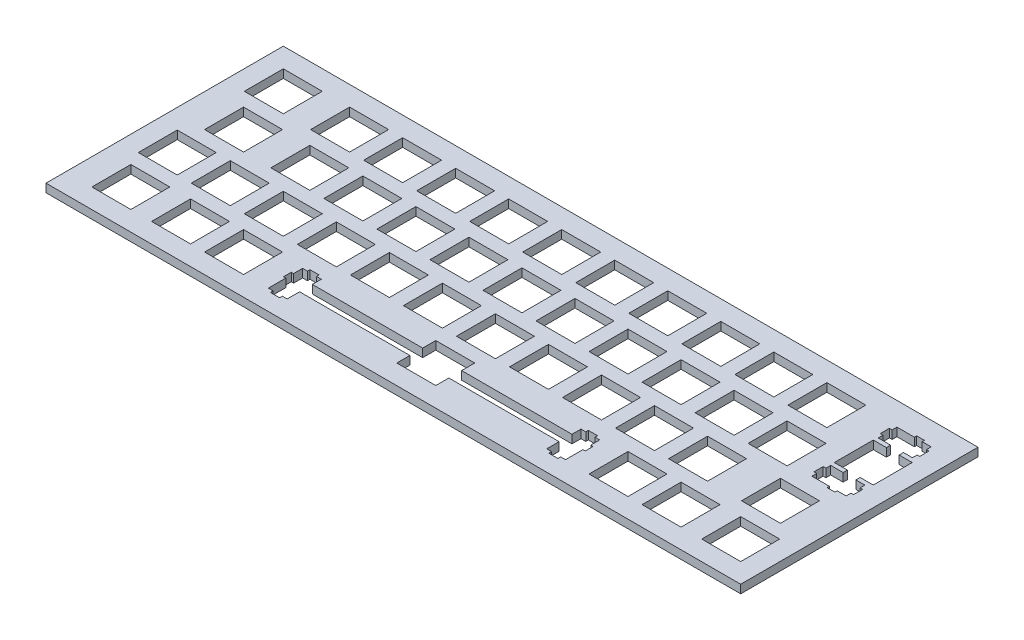
from build123d import *

# Parameters (mm, degrees)
ESQUISSE4_W        = 249.55535
ESQUISSE4_H        = 85.24946
ESQUISSE4_W_2      = 13.999
ESQUISSE4_H_2      = 13.99946
ESQUISSE4_W_3      = 13.9993
ESQUISSE4_W_4      = 13.99949
ESQUISSE4_W_5      = 14.001
ESQUISSE4_H_3      = 13.9994
ESQUISSE4_W_6      = 14.0007
ESQUISSE4_W_7      = 13.99955
ESQUISSE4_H_4      = 13.9993
ESQUISSE4_W_8      = 13.99954
ESQUISSE4_W_9      = 14
BOSS_EXTRU_2_DEPTH = 3


with BuildPart() as part:
    # Esquisse4 → Boss.-Extru.2 (new body)
    with BuildSketch(Plane(origin=(0, 0, 0), x_dir=(1, 0, 0), z_dir=(0, 1, 0))):
        with Locations((120.347325, 38.35837)):
            Rectangle(ESQUISSE4_W, ESQUISSE4_H)
        Polygon((114.537, 16.7831), (114.537, 12.0826), (74.9131, 12.0826), (74.9131, 15.3128), (73.1876, 15.3128), (73.1876, 16.2347), (69.887, 16.2347), (69.887, 15.3128), (68.162, 15.3128), (68.162, 12.0826), (67.3379, 12.0826), (67.3379, 9.28384), (68.162, 9.28384), (68.162, 3.01377), (69.887, 3.01377), (69.887, 2.03261), (73.1876, 2.03261), (73.1876, 3.01377), (74.9131, 3.01377), (74.9131, 7.48273), (114.537, 7.48273), (114.537, 2.78364), (128.538, 2.78364), (128.538, 7.48273), (168.162, 7.48273), (168.162, 3.01377), (169.887, 3.01377), (169.887, 2.03261), (173.188, 2.03261), (173.188, 3.01377), (174.913, 3.01377), (174.913, 9.28384), (175.737, 9.28384), (175.737, 12.0826), (174.913, 12.0826), (174.913, 15.3128), (173.188, 15.3128), (173.188, 16.2347), (169.887, 16.2347), (169.887, 15.3128), (168.162, 15.3128), (168.162, 12.0826), (128.538, 12.0826), (128.538, 16.7831), align=None, mode=Mode.SUBTRACT)
        with Locations((231.0755, 9.78337)):
            Rectangle(ESQUISSE4_W_2, ESQUISSE4_H_2, mode=Mode.SUBTRACT)
        with Locations((209.6445, 9.78337)):
            Rectangle(ESQUISSE4_W_2, ESQUISSE4_H_2, mode=Mode.SUBTRACT)
        with Locations((190.5945, 9.78337)):
            Rectangle(ESQUISSE4_W_2, ESQUISSE4_H_2, mode=Mode.SUBTRACT)
        with Locations((52.48185, 9.78337)):
            Rectangle(ESQUISSE4_W_3, ESQUISSE4_H_2, mode=Mode.SUBTRACT)
        with Locations((33.43185, 9.78337)):
            Rectangle(ESQUISSE4_W_3, ESQUISSE4_H_2, mode=Mode.SUBTRACT)
        with Locations((12.000655, 9.78337)):
            Rectangle(ESQUISSE4_W_4, ESQUISSE4_H_2, mode=Mode.SUBTRACT)
        with Locations((226.3125, 28.8333)):
            Rectangle(ESQUISSE4_W_5, ESQUISSE4_H_3, mode=Mode.SUBTRACT)
        with Locations((200.1195, 28.8333)):
            Rectangle(ESQUISSE4_W_2, ESQUISSE4_H_3, mode=Mode.SUBTRACT)
        with Locations((181.0695, 28.8333)):
            Rectangle(ESQUISSE4_W_2, ESQUISSE4_H_3, mode=Mode.SUBTRACT)
        with Locations((162.0195, 28.8333)):
            Rectangle(ESQUISSE4_W_2, ESQUISSE4_H_3, mode=Mode.SUBTRACT)
        with Locations((142.9695, 28.8333)):
            Rectangle(ESQUISSE4_W_2, ESQUISSE4_H_3, mode=Mode.SUBTRACT)
        with Locations((123.9185, 28.8333)):
            Rectangle(ESQUISSE4_W_5, ESQUISSE4_H_3, mode=Mode.SUBTRACT)
        with Locations((104.86865, 28.8333)):
            Rectangle(ESQUISSE4_W_6, ESQUISSE4_H_3, mode=Mode.SUBTRACT)
        with Locations((85.81935, 28.8333)):
            Rectangle(ESQUISSE4_W_3, ESQUISSE4_H_3, mode=Mode.SUBTRACT)
        with Locations((66.76935, 28.8333)):
            Rectangle(ESQUISSE4_W_3, ESQUISSE4_H_3, mode=Mode.SUBTRACT)
        with Locations((47.71935, 28.8333)):
            Rectangle(ESQUISSE4_W_3, ESQUISSE4_H_3, mode=Mode.SUBTRACT)
        with Locations((28.66935, 28.8333)):
            Rectangle(ESQUISSE4_W_3, ESQUISSE4_H_3, mode=Mode.SUBTRACT)
        with Locations((9.619425, 28.8333)):
            Rectangle(ESQUISSE4_W_7, ESQUISSE4_H_3, mode=Mode.SUBTRACT)
        with Locations((209.6445, 47.88345)):
            Rectangle(ESQUISSE4_W_2, ESQUISSE4_H_4, mode=Mode.SUBTRACT)
        with Locations((190.5945, 47.88345)):
            Rectangle(ESQUISSE4_W_2, ESQUISSE4_H_4, mode=Mode.SUBTRACT)
        with Locations((171.5445, 47.88345)):
            Rectangle(ESQUISSE4_W_2, ESQUISSE4_H_4, mode=Mode.SUBTRACT)
        with Locations((152.4945, 47.88345)):
            Rectangle(ESQUISSE4_W_2, ESQUISSE4_H_4, mode=Mode.SUBTRACT)
        with Locations((133.4445, 47.88345)):
            Rectangle(ESQUISSE4_W_2, ESQUISSE4_H_4, mode=Mode.SUBTRACT)
        with Locations((114.3945, 47.88345)):
            Rectangle(ESQUISSE4_W_2, ESQUISSE4_H_4, mode=Mode.SUBTRACT)
        with Locations((95.34435, 47.88345)):
            Rectangle(ESQUISSE4_W_3, ESQUISSE4_H_4, mode=Mode.SUBTRACT)
        with Locations((76.29435, 47.88345)):
            Rectangle(ESQUISSE4_W_3, ESQUISSE4_H_4, mode=Mode.SUBTRACT)
        with Locations((57.24435, 47.88345)):
            Rectangle(ESQUISSE4_W_3, ESQUISSE4_H_4, mode=Mode.SUBTRACT)
        with Locations((38.19435, 47.88345)):
            Rectangle(ESQUISSE4_W_3, ESQUISSE4_H_4, mode=Mode.SUBTRACT)
        with Locations((14.38193, 47.88345)):
            Rectangle(ESQUISSE4_W_8, ESQUISSE4_H_4, mode=Mode.SUBTRACT)
        Polygon((230.576, 73.5087), (230.576, 72.6832), (224.306, 72.6832), (224.306, 70.9581), (223.325, 70.9581), (223.325, 67.6589), (224.306, 67.6589), (224.306, 65.9335), (228.775, 65.9335), (228.775, 64.4081), (224.076, 64.4081), (224.076, 50.4088), (228.775, 50.4088), (228.775, 48.883), (224.306, 48.883), (224.306, 47.1579), (223.325, 47.1579), (223.325, 43.8587), (224.306, 43.8587), (224.306, 42.1337), (230.576, 42.1337), (230.576, 41.3082), (233.375, 41.3082), (233.375, 42.1337), (236.605, 42.1337), (236.605, 43.8587), (237.526, 43.8587), (237.526, 47.1579), (236.605, 47.1579), (236.605, 48.883), (233.375, 48.883), (233.375, 50.4088), (238.075, 50.4088), (238.075, 64.4081), (233.375, 64.4081), (233.375, 65.9335), (236.605, 65.9335), (236.605, 67.6589), (237.526, 67.6589), (237.526, 70.9581), (236.605, 70.9581), (236.605, 72.6832), (233.375, 72.6832), (233.375, 73.5087), align=None, mode=Mode.SUBTRACT)
        with Locations((204.882, 66.93345)):
            Rectangle(ESQUISSE4_W_9, ESQUISSE4_H_4, mode=Mode.SUBTRACT)
        with Locations((185.832, 66.93345)):
            Rectangle(ESQUISSE4_W_9, ESQUISSE4_H_4, mode=Mode.SUBTRACT)
        with Locations((166.782, 66.93345)):
            Rectangle(ESQUISSE4_W_9, ESQUISSE4_H_4, mode=Mode.SUBTRACT)
        with Locations((147.732, 66.93345)):
            Rectangle(ESQUISSE4_W_9, ESQUISSE4_H_4, mode=Mode.SUBTRACT)
        with Locations((128.682, 66.93345)):
            Rectangle(ESQUISSE4_W_9, ESQUISSE4_H_4, mode=Mode.SUBTRACT)
        with Locations((109.632, 66.93345)):
            Rectangle(ESQUISSE4_W_9, ESQUISSE4_H_4, mode=Mode.SUBTRACT)
        with Locations((90.58185, 66.93345)):
            Rectangle(ESQUISSE4_W_3, ESQUISSE4_H_4, mode=Mode.SUBTRACT)
        with Locations((71.53185, 66.93345)):
            Rectangle(ESQUISSE4_W_3, ESQUISSE4_H_4, mode=Mode.SUBTRACT)
        with Locations((52.48185, 66.93345)):
            Rectangle(ESQUISSE4_W_3, ESQUISSE4_H_4, mode=Mode.SUBTRACT)
        with Locations((33.43185, 66.93345)):
            Rectangle(ESQUISSE4_W_3, ESQUISSE4_H_4, mode=Mode.SUBTRACT)
        with Locations((9.619425, 66.93345)):
            Rectangle(ESQUISSE4_W_7, ESQUISSE4_H_4, mode=Mode.SUBTRACT)
    extrude(amount=BOSS_EXTRU_2_DEPTH)


solid = part.part
